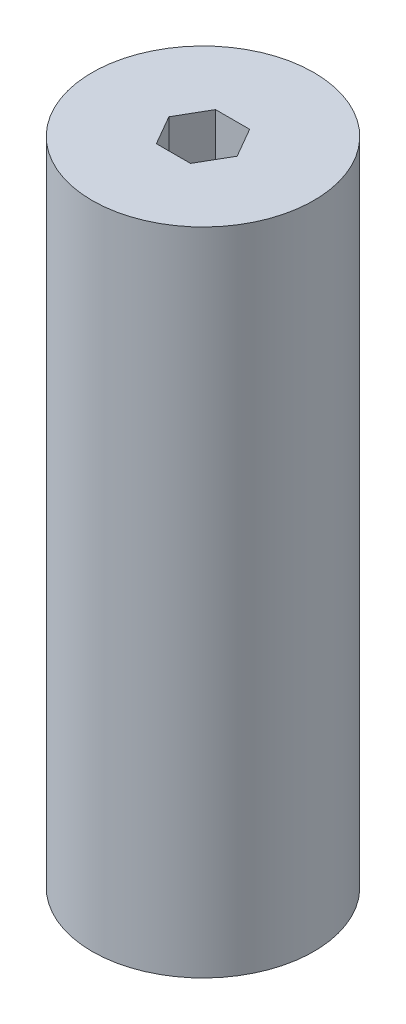
from build123d import *

# Parameters (mm, degrees)
SKETCH1_R           = 23.8125
BOSS_EXTRUDE1_DEPTH = 139.7


with BuildPart() as part:
    # Sketch1 → Boss-Extrude1 (new body)
    with BuildSketch(Plane(origin=(0, 0, 0), x_dir=(1, 0, 0), z_dir=(0, 1, 0))):
        Circle(SKETCH1_R)
        Polygon((3.666174209, -6.35), (7.332348419, 0), (3.666174209, 6.35), (-3.666174209, 6.35), (-7.332348419, 0), (-3.666174209, -6.35), align=None, mode=Mode.SUBTRACT)
    extrude(amount=BOSS_EXTRUDE1_DEPTH)


solid = part.part
